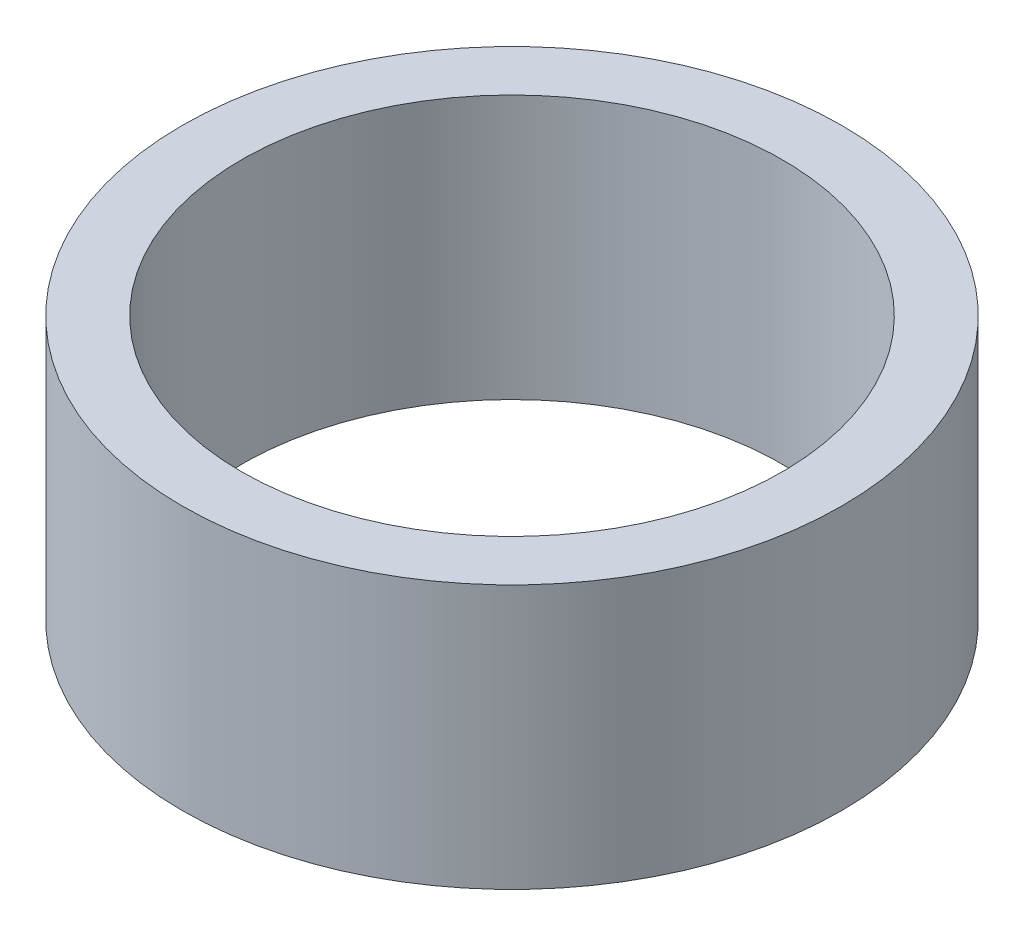
from build123d import *

# Parameters (mm, degrees)
SKETCH1_W = 0.9
SKETCH1_H = 4


with BuildPart() as part:
    # Sketch1 → Revolve1 (revolve)
    with BuildSketch(Plane.XY):
        with Locations((4.55, 0)):
            Rectangle(SKETCH1_W, SKETCH1_H)
    revolve(axis=Axis((0, 13.009547281, 0), (0, -1, 0)))


solid = part.part
